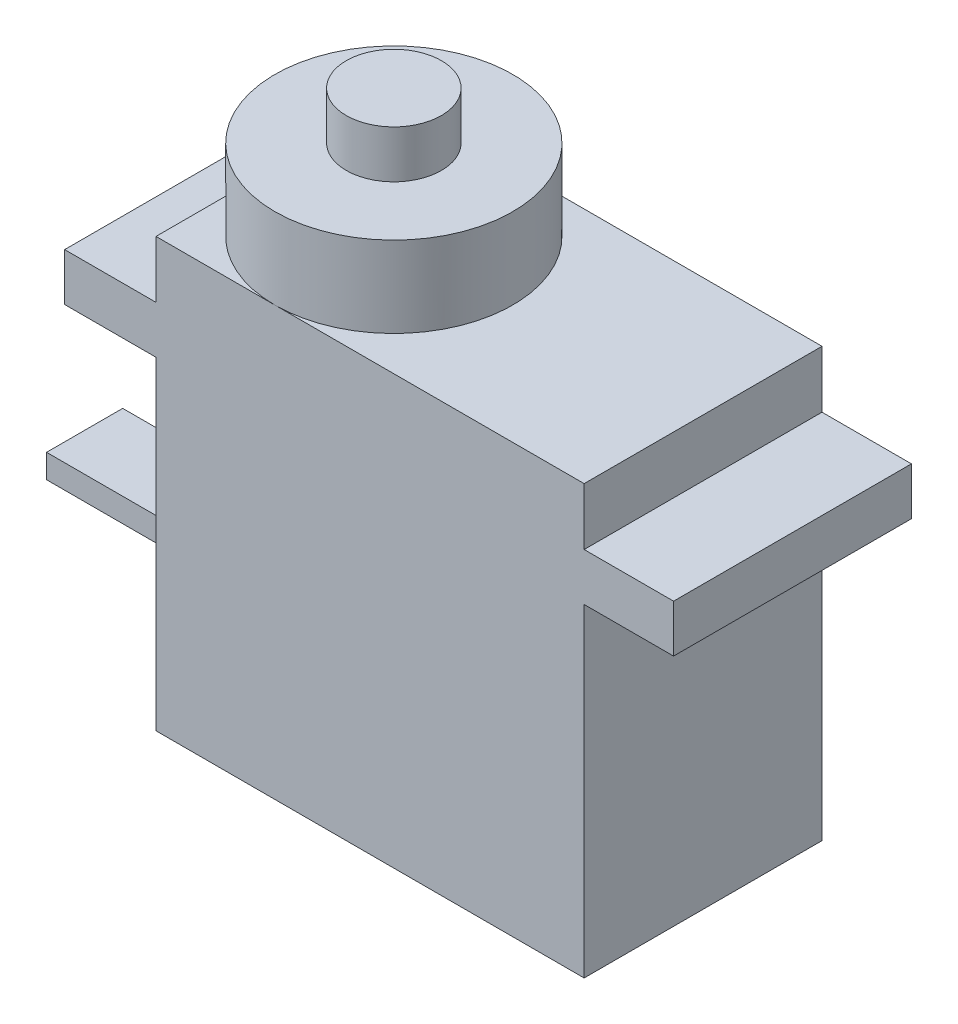
from build123d import *

# Parameters (mm, degrees)
SKETCH1_W           = 22.5
SKETCH1_H           = 12.5
BOSS_EXTRUDE1_DEPTH = 22.5
BOSS_EXTRUDE2_START = 17
SKETCH1_3_W         = 4.8
SKETCH1_3_H         = 12.5
SKETCH1_3_W_2       = 4.7
BOSS_EXTRUDE2_DEPTH = 2.5
SKETCH2_R           = 6.25
BOSS_EXTRUDE3_DEPTH = 4.25
SKETCH2_3_R         = 2.5
BOSS_EXTRUDE4_DEPTH = 6.75
SKETCH3_W           = 4
SKETCH3_H           = 1.25
BOSS_EXTRUDE5_DEPTH = 10


with BuildPart() as part:
    # Sketch1 → Boss-Extrude1 (new body)
    with BuildSketch(Plane(origin=(0, 0, 0), x_dir=(1, 0, 0), z_dir=(0, 1, 0))):
        with Locations((11.25, 6.25)):
            Rectangle(SKETCH1_W, SKETCH1_H)
    extrude(amount=BOSS_EXTRUDE1_DEPTH)

    # Sketch1_3 → Boss-Extrude2 (add)
    with BuildSketch(Plane(origin=(0, 0, 0), x_dir=(1, 0, 0), z_dir=(0, 1, 0)).offset(BOSS_EXTRUDE2_START)):
        with Locations((-2.4, 6.25)):
            Rectangle(SKETCH1_3_W, SKETCH1_3_H)
        with Locations((24.85, 6.25)):
            Rectangle(SKETCH1_3_W_2, SKETCH1_3_H)
    extrude(amount=BOSS_EXTRUDE2_DEPTH)

    # Sketch2 → Boss-Extrude3 (add)
    with BuildSketch(Plane(origin=(0, 22.5, 0), x_dir=(1, 0, 0), z_dir=(0, 1, 0))):
        with Locations((6.25, 6.25)):
            Circle(SKETCH2_R)
    extrude(amount=BOSS_EXTRUDE3_DEPTH)

    # Sketch2_3 → Boss-Extrude4 (add)
    with BuildSketch(Plane(origin=(0, 22.5, 0), x_dir=(1, 0, 0), z_dir=(0, 1, 0))):
        with Locations((6.25, 6.25)):
            Circle(SKETCH2_3_R)
    extrude(amount=BOSS_EXTRUDE4_DEPTH)

    # Sketch3 → Boss-Extrude5 (add)
    with BuildSketch(Plane.ZY):
        with Locations((-6.25, 4.925)):
            Rectangle(SKETCH3_W, SKETCH3_H)
    extrude(amount=BOSS_EXTRUDE5_DEPTH)


solid = part.part
